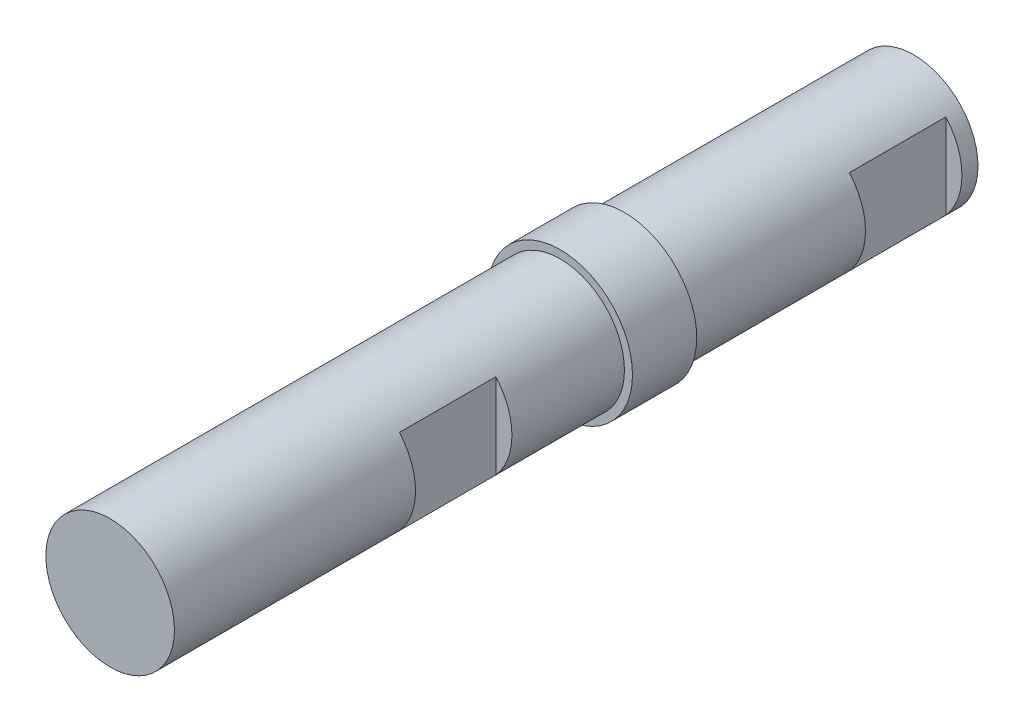
from build123d import *

# Parameters (mm, degrees)
SKETCH_1_R          = 4
EXTRUDE_1_DEPTH     = 18
SKETCH_2_R          = 4.5
EXTRUDE_2_DEPTH     = 4
SKETCH_3_R          = 4
EXTRUDE_3_DEPTH     = 28
SKETCH_4_W          = 6
SKETCH_4_H          = 6
CUT_EXTRUDE_1_DEPTH = 1
SKETCH_5_W          = 6
SKETCH_5_H          = 6
CUT_EXTRUDE_2_DEPTH = 1


with BuildPart() as part:
    # 草圖1 → 填料-伸長1 (new body)
    with BuildSketch(Plane.XY):
        Circle(SKETCH_1_R)
    extrude(amount=EXTRUDE_1_DEPTH)

    # 草圖2 → 填料-伸長2 (add)
    with BuildSketch(Plane.XY.offset(18)):
        Circle(SKETCH_2_R)
    extrude(amount=EXTRUDE_2_DEPTH)

    # 草圖3 → 填料-伸長3 (add)
    with BuildSketch(Plane.XY.offset(22)):
        Circle(SKETCH_3_R)
    extrude(amount=EXTRUDE_3_DEPTH)

    # 草圖4 → 除料-伸長1 (cut)
    with BuildSketch(Plane(origin=(4, 0, 0), x_dir=(0, 0, -1), z_dir=(1, 0, 0))):
        with Locations((-32, 0)):
            Rectangle(SKETCH_4_W, SKETCH_4_H)
    extrude(amount=-CUT_EXTRUDE_1_DEPTH, mode=Mode.SUBTRACT)

    # 草圖5 → 除料-伸長2 (cut)
    with BuildSketch(Plane(origin=(4, 0, 0), x_dir=(0, 0, -1), z_dir=(1, 0, 0))):
        with Locations((-4, 0)):
            Rectangle(SKETCH_5_W, SKETCH_5_H)
    extrude(amount=-CUT_EXTRUDE_2_DEPTH, mode=Mode.SUBTRACT)


solid = part.part
